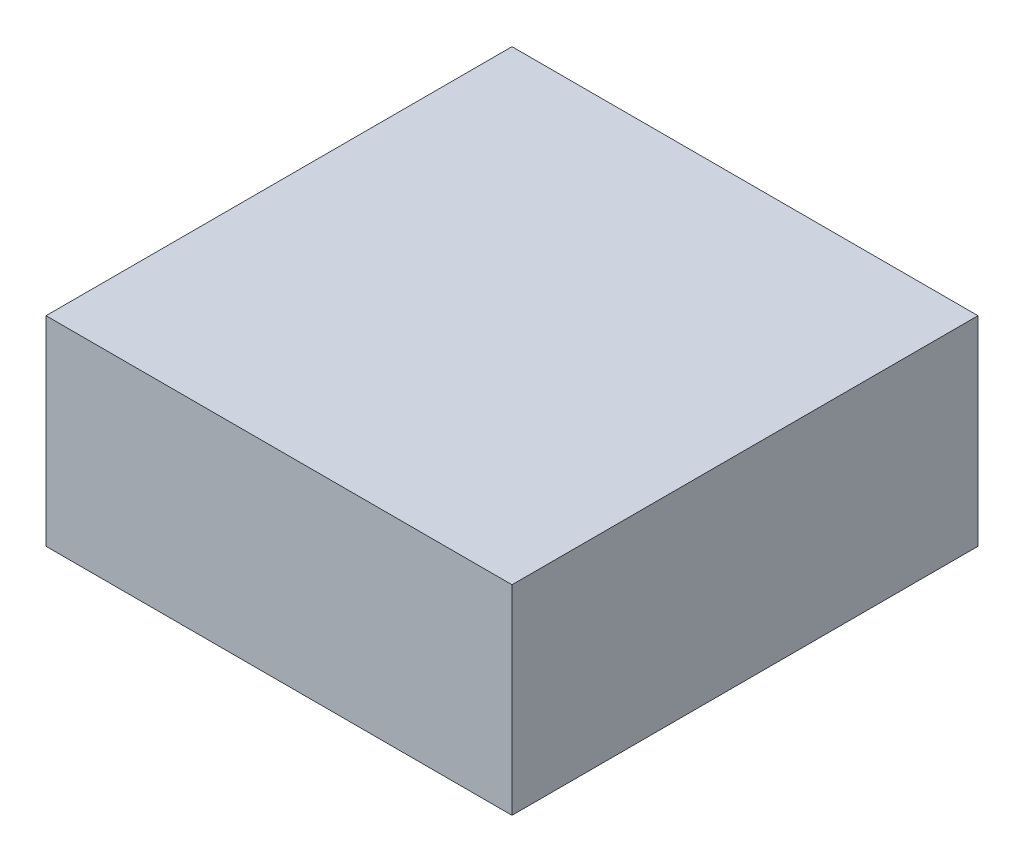
from build123d import *

# Parameters (mm, degrees)
SKETCH1_W           = 88.9
SKETCH1_H           = 88.9
BOSS_EXTRUDE1_DEPTH = 38.1


with BuildPart() as part:
    # Sketch1 → Boss-Extrude1 (new body)
    with BuildSketch(Plane(origin=(0, 0, 0), x_dir=(1, 0, 0), z_dir=(0, 1, 0))):
        with Locations((44.45, -44.45)):
            Rectangle(SKETCH1_W, SKETCH1_H)
    extrude(amount=BOSS_EXTRUDE1_DEPTH)


solid = part.part
